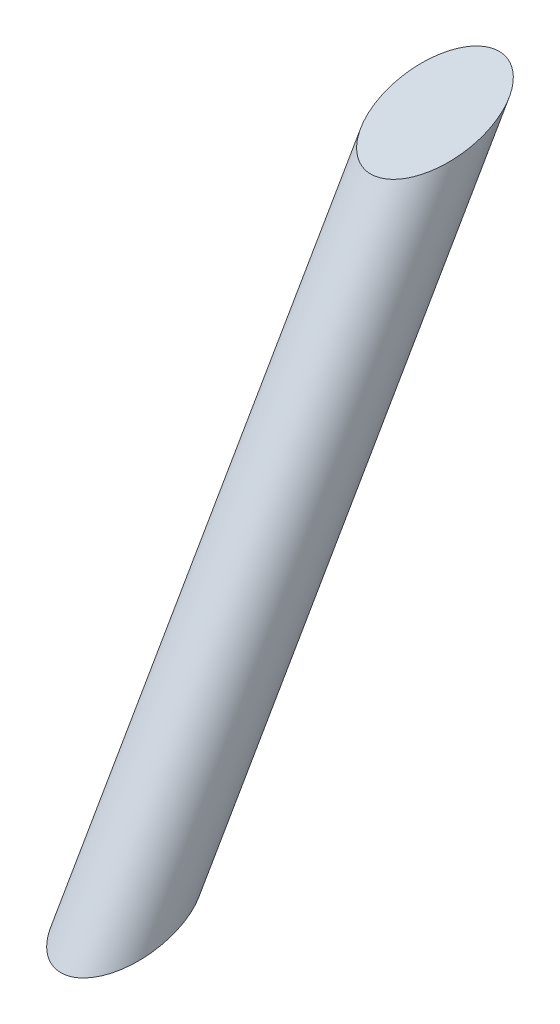
from build123d import *

# Parameters (mm, degrees)
KES_EKSTR_ZYON1_DEPTH      = 10
KES_EKSTR_ZYON1_DEPTH_BACK = 10


with BuildPart() as part:
    # Çizim1 → Döndür-İnce1 (revolve)
    with BuildSketch(Plane(origin=(0, 0, 0), x_dir=(0, 0, -1), z_dir=(1, 0, 0))):
        Polygon((-24.827612123, -44.26658513), (55.172387877, 94.297479476), (46.51213384, 99.297479476), (-33.48786616, -39.26658513), align=None)
    revolve(axis=Axis((0, -44.26658513, 24.827612123), (0, 0.8660254037844387, -0.5000000000000001)))

    # Çizim3 → Kes-Ekstrüzyon1 (cut, two sides: drawn at the far end of the back side and taken through both)
    with BuildSketch(Plane(origin=(0, 0, 0), x_dir=(0, 0, -1), z_dir=(1, 0, 0)).offset(-KES_EKSTR_ZYON1_DEPTH_BACK)):
        Polygon((63.832641915, 89.297479476), (46.51213384, 99.297479476), (35.331793952, 79.932562745), align=None)
        Polygon((-33.48786616, -39.26658513), (-16.167358085, -49.26658513), (-4.987018197, -29.901668399), align=None)
    extrude(amount=KES_EKSTR_ZYON1_DEPTH + KES_EKSTR_ZYON1_DEPTH_BACK, mode=Mode.SUBTRACT)


solid = part.part
